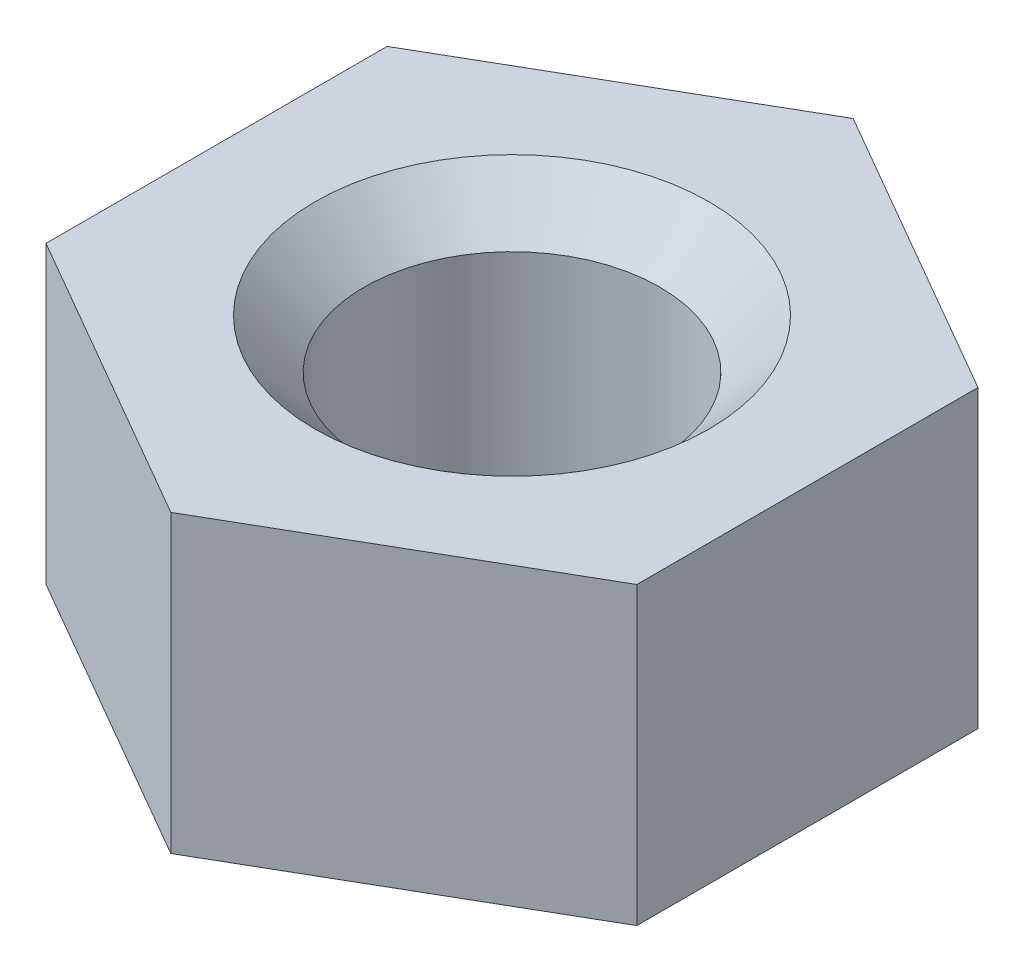
from build123d import *

# Parameters (mm, degrees)
BOSS_EXTRUDE1_DEPTH = 6
SKETCH2_R           = 3
CUT_EXTRUDE1_DEPTH  = 6
CHAMFER2_SIZE       = 1


with BuildPart() as part:
    # Sketch1 → Boss-Extrude1 (new body)
    with BuildSketch(Plane(origin=(0, 0, 0), x_dir=(1, 0, 0), z_dir=(0, 1, 0))):
        Polygon((0, 6.92820323), (-6, 3.464101615), (-6, -3.464101615), (0, -6.92820323), (6, -3.464101615), (6, 3.464101615), align=None)
    extrude(amount=BOSS_EXTRUDE1_DEPTH)

    # Sketch2 → Cut-Extrude1 (cut)
    with BuildSketch(Plane(origin=(0, 6, 0), x_dir=(1, 0, 0), z_dir=(0, 1, 0))):
        Circle(SKETCH2_R)
    extrude(amount=-CUT_EXTRUDE1_DEPTH, mode=Mode.SUBTRACT)

    # Chamfer2
    chamfer2_edges = [part.edges().sort_by_distance(p)[0] for p in [
        (-3, 0, 0),
        (-3, 6, 0),
    ]]
    chamfer(chamfer2_edges, length=CHAMFER2_SIZE)


solid = part.part
